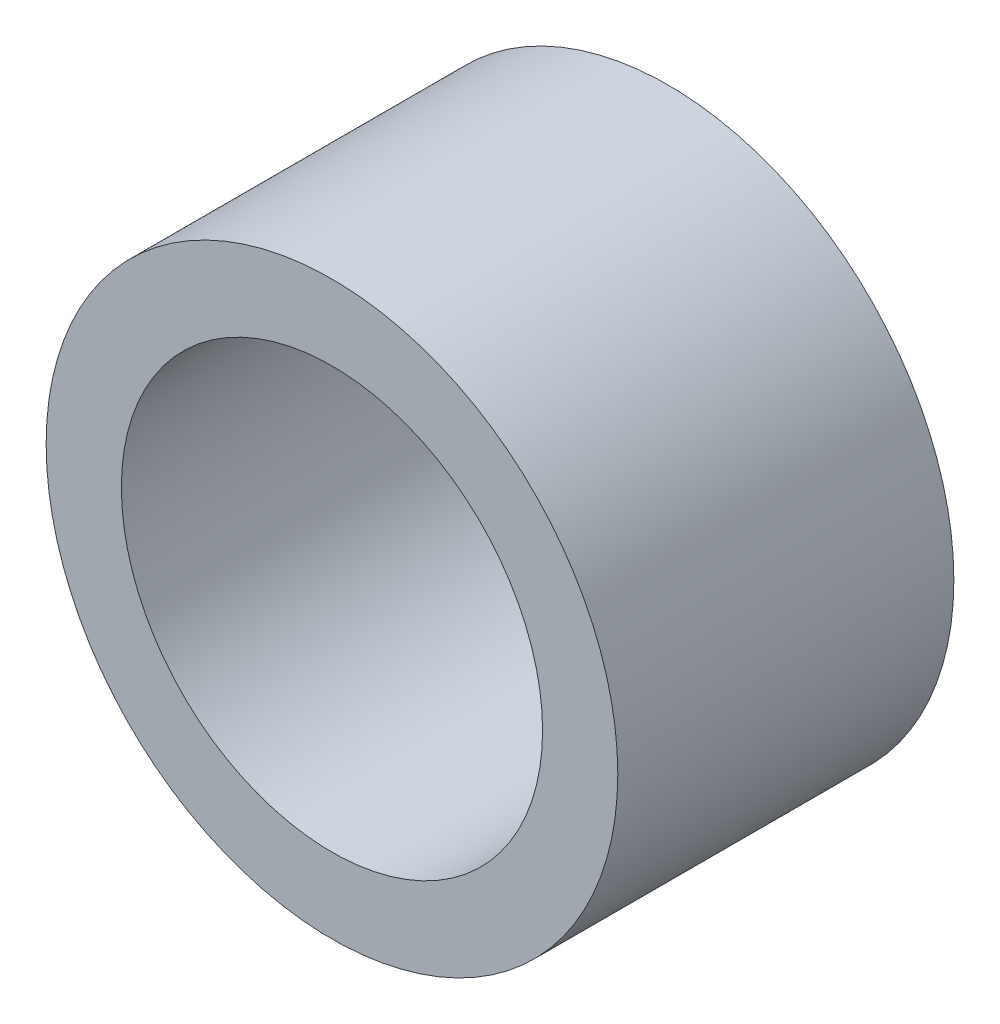
from build123d import *

# Parameters (mm, degrees)
SKETCH1_R           = 4.826
SKETCH1_R_2         = 3.556
BOSS_EXTRUDE1_DEPTH = 5.67436


with BuildPart() as part:
    # Sketch1 → Boss-Extrude1 (new body)
    with BuildSketch(Plane.XY):
        Circle(SKETCH1_R)
        Circle(SKETCH1_R_2, mode=Mode.SUBTRACT)
    extrude(amount=BOSS_EXTRUDE1_DEPTH)


solid = part.part
